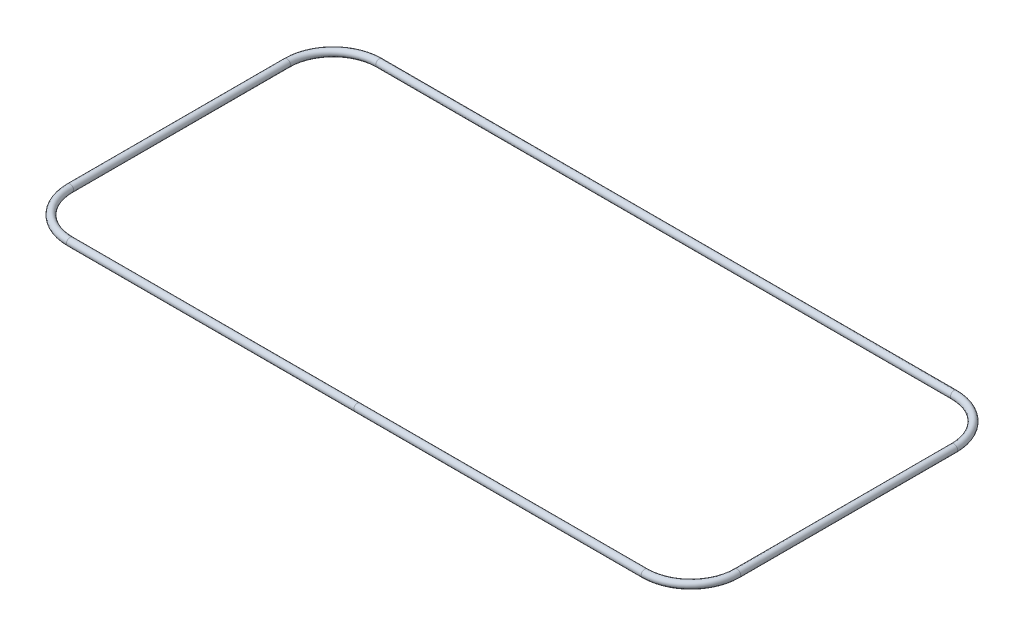
from build123d import *

# Parameters (mm, degrees)
SKETCH2_R = 1.7653


with BuildPart() as part:
    # Sweep1: sweep along a path in Sketch1
    with BuildLine(Plane(origin=(0, 0, 0), x_dir=(1, 0, 0), z_dir=(0, 1, 0))) as sweep1_path:
        Line((-142.799128817, 75.082728817), (142.799128817, 75.082728817))
        ThreePointArc((142.799128817, 75.082728817), (157.778196027, 68.878196027), (163.982728817, 53.899128817))
        Line((163.982728817, 53.899128817), (163.982728817, -53.899128817))
        ThreePointArc((163.982728817, -53.899128817), (157.778196027, -68.878196027), (142.799128817, -75.082728817))
        Line((142.799128817, -75.082728817), (-142.799128817, -75.082728817))
        ThreePointArc((-142.799128817, -75.082728817), (-157.778196027, -68.878196027), (-163.982728817, -53.899128817))
        Line((-163.982728817, -53.899128817), (-163.982728817, 53.899128817))
        ThreePointArc((-163.982728817, 53.899128817), (-157.778196027, 68.878196027), (-142.799128817, 75.082728817))
    # Sketch2 → Sweep1 (sweep)
    with BuildSketch(Plane(origin=(0, 0, 0), x_dir=(0, 0, -1), z_dir=(1, 0, 0))):
        with Locations((-76.848028817, 0)):
            Circle(SKETCH2_R)
    sweep(path=sweep1_path.line)


solid = part.part
